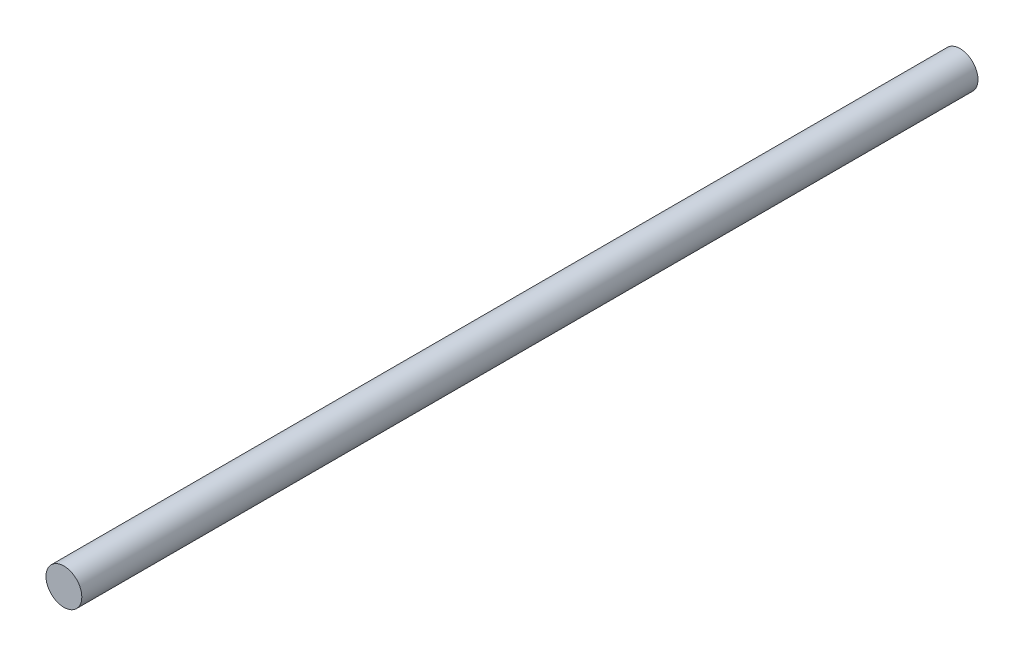
from build123d import *

# Parameters (mm, degrees)
SKETCH1_R           = 10
BOSS_EXTRUDE1_DEPTH = 500


with BuildPart() as part:
    # Sketch1 → Boss-Extrude1 (new body)
    with BuildSketch(Plane.XY):
        Circle(SKETCH1_R)
    extrude(amount=BOSS_EXTRUDE1_DEPTH)


solid = part.part
